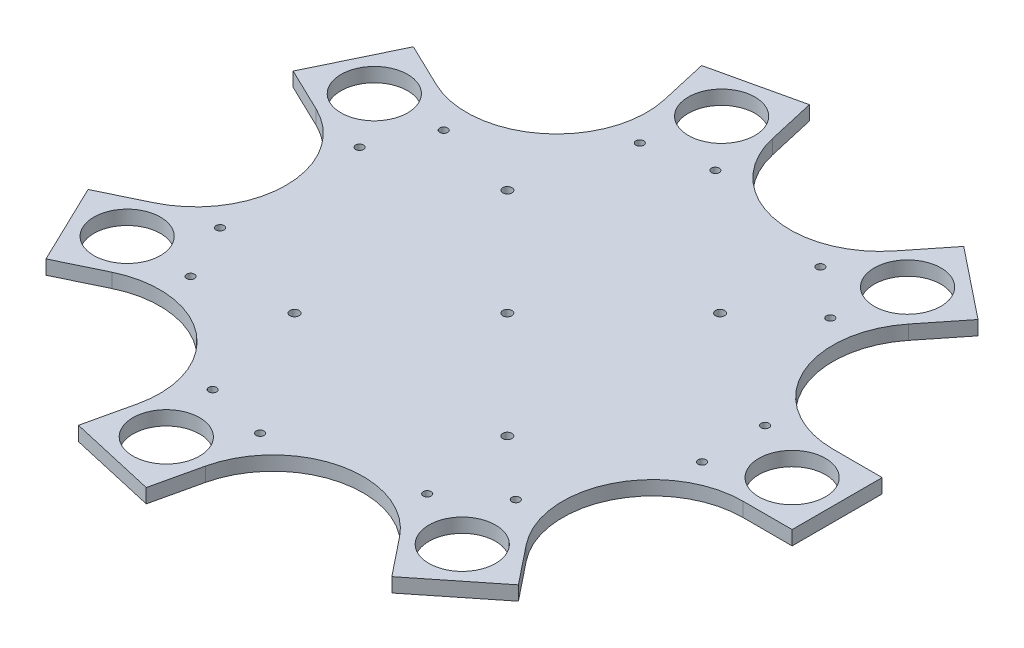
from build123d import *

# Parameters (mm, degrees)
SKETCH3_W           = 232.55
SKETCH3_H           = 63.5
SKETCH3_R           = 2.778125
SKETCH3_R_2         = 23.495
BOSS_EXTRUDE1_DEPTH = 10
CIRPATTERN1_COUNT   = 7
FILLET1_R           = 63.5
SKETCH4_R           = 3.25
CUT_EXTRUDE1_DEPTH  = 11


with BuildPart() as part:
    # Sketch3 → Boss-Extrude1 (new body)
    with BuildSketch(Plane(origin=(0, 0, 0), x_dir=(1, 0, 0), z_dir=(0, 1, 0))):
        with Locations((116.275, 0)):
            Rectangle(SKETCH3_W, SKETCH3_H)
        with Locations((159.525, 22.225)):
            Circle(SKETCH3_R, mode=Mode.SUBTRACT)
        with Locations((159.525, -22.225)):
            Circle(SKETCH3_R, mode=Mode.SUBTRACT)
        with Locations((200.8, 0)):
            Circle(SKETCH3_R_2, mode=Mode.SUBTRACT)
    boss_extrude1 = extrude(amount=BOSS_EXTRUDE1_DEPTH)

    # CirPattern1: Boss-Extrude1 ×7 about axis
    cirpattern1_axis = Axis((0, 0, 0), (0, 1, 0))
    for i in range(1, CIRPATTERN1_COUNT):
        add(boss_extrude1.rotate(cirpattern1_axis, i * 360 / CIRPATTERN1_COUNT))

    # Fillet1
    fillet1_edges = [part.edges().sort_by_distance(p)[0] for p in [
        (65.929554341, 5, 31.75),
        (65.929554341, 5, -31.75),
        (16.283255204, 5, 71.341602418),
        (-45.624667219, 5, 57.211523112),
        (-73.176284653, 5, 0),
        (-45.624667219, 5, -57.211523112),
        (16.283255204, 5, -71.341602418),
    ]]
    fillet(fillet1_edges, radius=FILLET1_R)

    # Sketch4 → Cut-Extrude1 (cut, through all)
    with BuildSketch(Plane(origin=(0, 0, 0), x_dir=(1, 0, 0), z_dir=(0, 1, 0))):
        with Locations((75, 75)):
            Circle(SKETCH4_R)
        with Locations((75, -75)):
            Circle(SKETCH4_R)
        with Locations((-75, -75)):
            Circle(SKETCH4_R)
        with Locations((-75, 75)):
            Circle(SKETCH4_R)
        Circle(SKETCH4_R)
    extrude(amount=CUT_EXTRUDE1_DEPTH, mode=Mode.SUBTRACT)


solid = part.part
